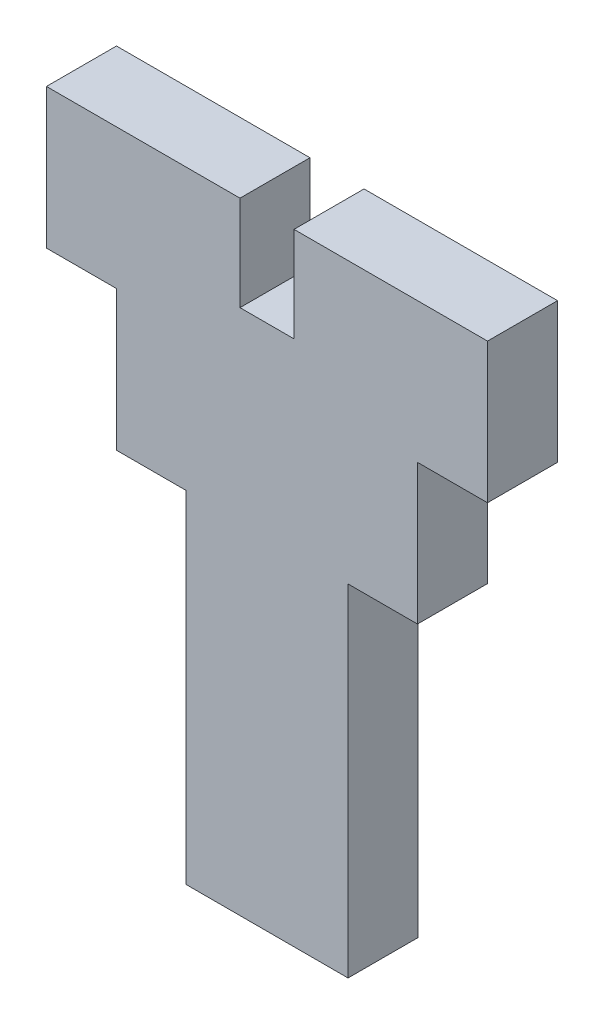
from build123d import *

# Parameters (mm, degrees)
SKETCH2_W           = 40
SKETCH2_H           = 12.7
BOSS_EXTRUDE1_DEPTH = 6.35
SKETCH3_W           = 27.3
SKETCH3_H           = 6.35
BOSS_EXTRUDE2_DEPTH = 12.7
SKETCH4_W           = 4.9
SKETCH4_H           = 6.35
CUT_EXTRUDE1_DEPTH  = 8.6
SKETCH5_W           = 14.7
SKETCH5_H           = 6.35
BOSS_EXTRUDE3_DEPTH = 30.95


with BuildPart() as part:
    # Sketch2 → Boss-Extrude1 (new body)
    with BuildSketch(Plane.XY):
        Rectangle(SKETCH2_W, SKETCH2_H)
    extrude(amount=BOSS_EXTRUDE1_DEPTH)

    # Sketch3 → Boss-Extrude2 (add)
    with BuildSketch(Plane.XZ.offset(6.35)):
        with Locations((0, 3.175)):
            Rectangle(SKETCH3_W, SKETCH3_H)
    extrude(amount=BOSS_EXTRUDE2_DEPTH)

    # Sketch4 → Cut-Extrude1 (cut)
    with BuildSketch(Plane(origin=(0, 6.35, 0), x_dir=(1, 0, 0), z_dir=(0, 1, 0))):
        with Locations((0, -3.175)):
            Rectangle(SKETCH4_W, SKETCH4_H)
    extrude(amount=-CUT_EXTRUDE1_DEPTH, mode=Mode.SUBTRACT)

    # Sketch5 → Boss-Extrude3 (add)
    with BuildSketch(Plane.XZ.offset(19.05)):
        with Locations((0, 3.175)):
            Rectangle(SKETCH5_W, SKETCH5_H)
    extrude(amount=BOSS_EXTRUDE3_DEPTH)


solid = part.part
